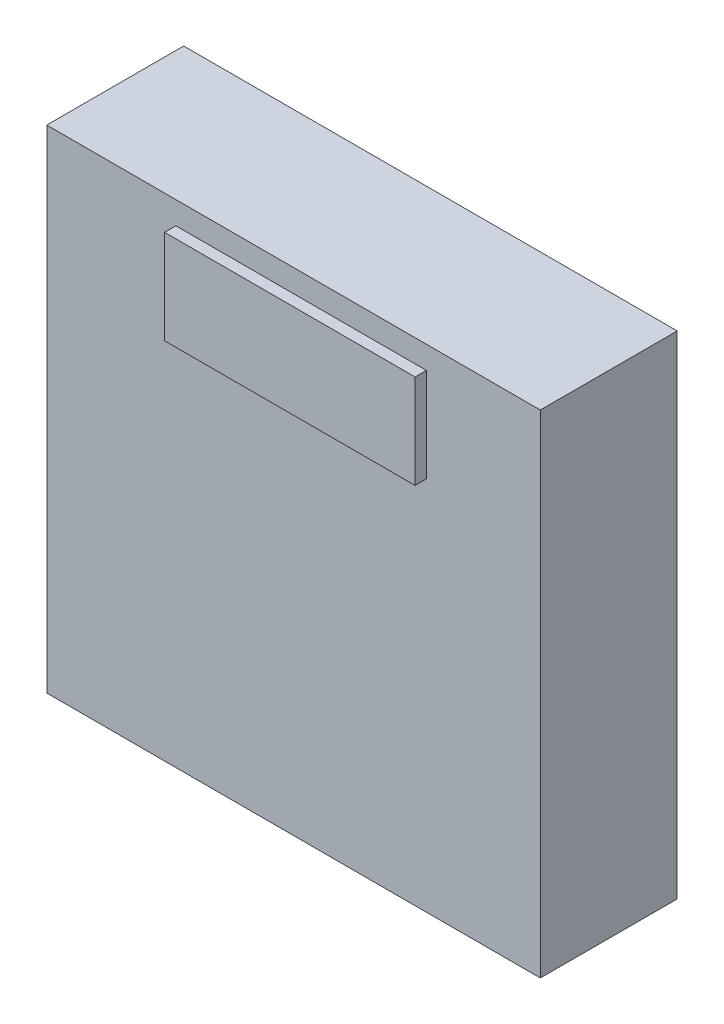
from build123d import *

# Parameters (mm, degrees)
SKETCH1_W           = 110.5916
SKETCH1_H           = 110.2233
BOSS_EXTRUDE1_DEPTH = 30.6832
SKETCH3_W           = 56.134
SKETCH3_H           = 21.0439
BOSS_EXTRUDE2_DEPTH = 2.54


with BuildPart() as part:
    # Sketch1 → Boss-Extrude1 (new body)
    with BuildSketch(Plane.XY):
        Rectangle(SKETCH1_W, SKETCH1_H)
    extrude(amount=BOSS_EXTRUDE1_DEPTH)

    # Sketch3 → Boss-Extrude2 (add)
    with BuildSketch(Plane.XY.offset(30.6832)):
        with Locations((1.7018, 39.5097)):
            Rectangle(SKETCH3_W, SKETCH3_H)
    extrude(amount=BOSS_EXTRUDE2_DEPTH)


solid = part.part
